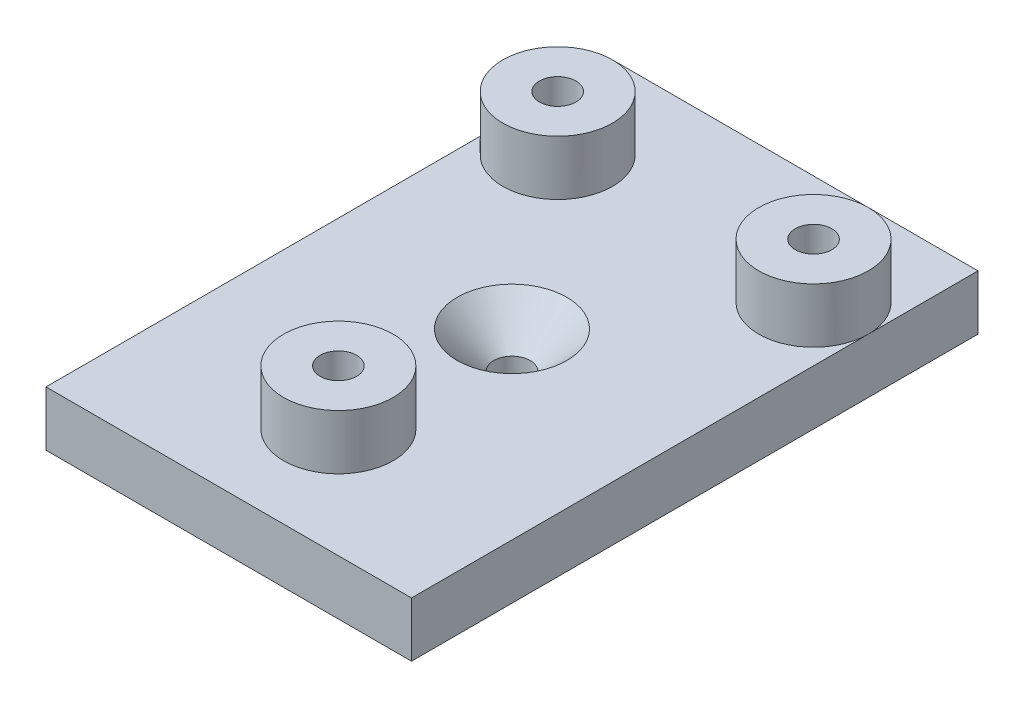
from build123d import *

# Parameters (mm, degrees)
SKETCH_1_W          = 20
SKETCH_1_H          = 31
EXTRUDE_1_DEPTH     = 3
SKETCH_3_R          = 3
SKETCH_3_R_2        = 1
EXTRUDE_2_DEPTH     = 3
SKETCH_4_R          = 1
CUT_EXTRUDE_1_DEPTH = 3
CHAMFER_1_SIZE      = 2


with BuildPart() as part:
    # Эскиз1 → Бобышка-Вытянуть1 (new body)
    with BuildSketch(Plane(origin=(0, 0, 0), x_dir=(1, 0, 0), z_dir=(0, 1, 0))):
        with Locations((-0.943604651, -8.91744186)):
            Rectangle(SKETCH_1_W, SKETCH_1_H)
    extrude(amount=EXTRUDE_1_DEPTH)

    # Эскиз3 → Бобышка-Вытянуть2 (add)
    with BuildSketch(Plane(origin=(0, 3, 0), x_dir=(1, 0, 0), z_dir=(0, 1, 0))):
        with Locations((-7.943604651, 0.58255814)):
            Circle(SKETCH_3_R)
        with Locations((-7.943604651, 0.58255814)):
            Circle(SKETCH_3_R_2, mode=Mode.SUBTRACT)
        with Locations((6.056395349, 0.58255814)):
            Circle(SKETCH_3_R)
        with Locations((6.056395349, 0.58255814)):
            Circle(SKETCH_3_R_2, mode=Mode.SUBTRACT)
        with Locations((-0.943604651, -18.41744186)):
            Circle(SKETCH_3_R)
        with Locations((-0.943604651, -18.41744186)):
            Circle(SKETCH_3_R_2, mode=Mode.SUBTRACT)
    extrude(amount=EXTRUDE_2_DEPTH)

    # Эскиз4 → Вырез-Вытянуть1 (cut)
    with BuildSketch(Plane(origin=(0, 3, 0), x_dir=(1, 0, 0), z_dir=(0, 1, 0))):
        with Locations((-0.943604651, -8.91744186)):
            Circle(SKETCH_4_R)
    extrude(amount=-CUT_EXTRUDE_1_DEPTH, mode=Mode.SUBTRACT)

    # Фаска1
    chamfer_1_edges = [part.edges().sort_by_distance(p)[0] for p in [
        (-1.943604651, 3, 8.91744186),
    ]]
    chamfer(chamfer_1_edges, length=CHAMFER_1_SIZE)


solid = part.part
